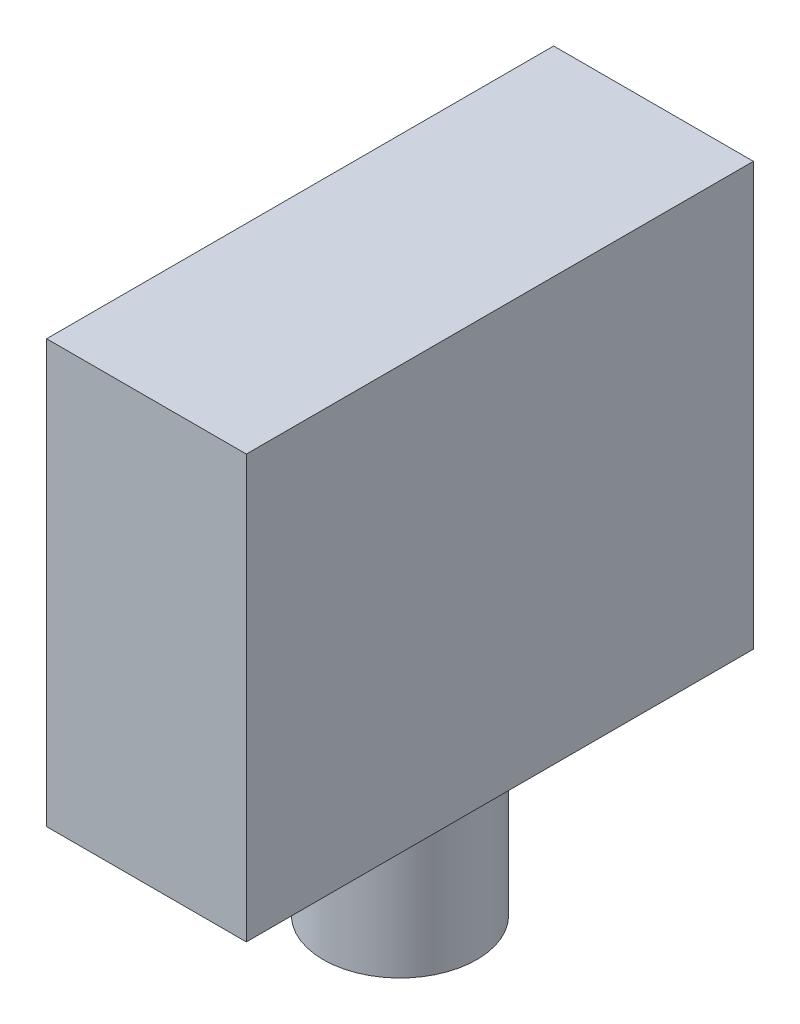
from build123d import *

# Parameters (mm, degrees)
SKIZZE1_W                       = 13
SKIZZE1_H                       = 33
AUFSATZ_LINEAR_AUSTRAGEN1_DEPTH = 27.5
SKIZZE2_R                       = 5
AUFSATZ_LINEAR_AUSTRAGEN2_DEPTH = 10


with BuildPart() as part:
    # Skizze1 → Aufsatz-Linear austragen1 (new body)
    with BuildSketch(Plane(origin=(0, 0, 0), x_dir=(1, 0, 0), z_dir=(0, 1, 0))):
        with Locations((-7.102941176, -3.558823529)):
            Rectangle(SKIZZE1_W, SKIZZE1_H)
    extrude(amount=AUFSATZ_LINEAR_AUSTRAGEN1_DEPTH)

    # Skizze2 → Aufsatz-Linear austragen2 (add)
    with BuildSketch(Plane(origin=(0, 0, 0), x_dir=(1, 0, 0), z_dir=(0, 1, 0))):
        with Locations((-7.102941176, -3.558823529)):
            Circle(SKIZZE2_R)
    extrude(amount=-AUFSATZ_LINEAR_AUSTRAGEN2_DEPTH)


solid = part.part
